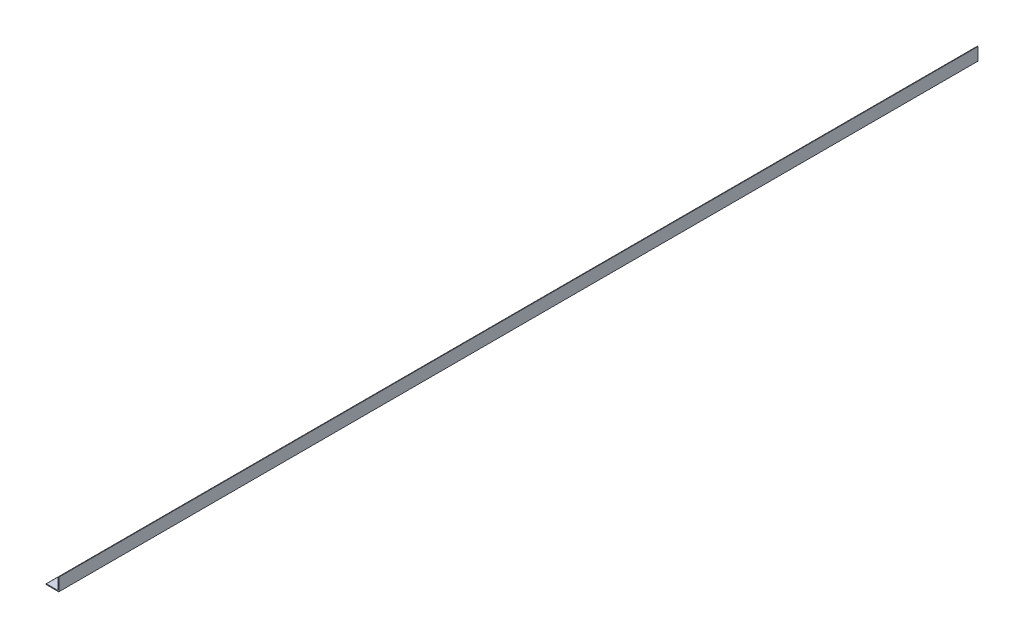
from build123d import *

# Parameters (mm, degrees)
BOSS_EXTRUDE1_DEPTH     = 914.4
F_1_4_20_TAPPED_HOLE1_D = 5.1054
CUT_EXTRUDE1_DEPTH      = 915.798166349


with BuildPart() as part:
    # Sketch2 → Boss-Extrude1 (new, symmetric)
    with BuildSketch(Plane.XY):
        with BuildLine():
            Line((-12.7, -12.7), (12.7, -12.7))
            Line((12.7, -12.7), (12.7, 12.7))
            Line((12.7, 12.7), (11.90625, 12.7))
            ThreePointArc((11.90625, 12.7), (11.344983992, 12.467516008), (11.1125, 11.90625))
            Line((11.1125, 11.90625), (11.1125, -9.5377))
            ThreePointArc((11.1125, -9.5377), (10.651251759, -10.651251759), (9.5377, -11.1125))
            Line((9.5377, -11.1125), (-11.90625, -11.1125))
            ThreePointArc((-11.90625, -11.1125), (-12.467516008, -11.344983992), (-12.7, -11.90625))
            Line((-12.7, -11.90625), (-12.7, -12.7))
        make_face()
    extrude(amount=BOSS_EXTRUDE1_DEPTH, both=True)

    # 1/4-20 Tapped Hole1 (through all)
    with Locations(Plane(origin=(0, -11.1125, 0), x_dir=(1, 0, 0), z_dir=(0, 1, 0))):
        with Locations((-1.5875, -705.104), (-1.5875, -249.428), (-1.5875, 661.924), (-1.5875, 206.248)):
            Hole(F_1_4_20_TAPPED_HOLE1_D / 2)

    # Sketch5 → Cut-Extrude1 (cut, through all)
    with BuildSketch(Plane(origin=(0, -11.1125, 0), x_dir=(1, 0, 0), z_dir=(0, 1, 0))):
        with BuildLine():
            Line((-4.6355, 701.675), (-4.6355, 720.725))
            ThreePointArc((-4.6355, 720.725), (-1.5875, 723.773), (1.4605, 720.725))
            Line((1.4605, 720.725), (1.4605, 701.675))
            ThreePointArc((1.4605, 701.675), (-1.5875, 698.627), (-4.6355, 701.675))
        make_face()
        with BuildLine():
            Line((1.4605, 304.8), (1.4605, 285.75))
            ThreePointArc((1.4605, 285.75), (-1.5875, 282.702), (-4.6355, 285.75))
            Line((-4.6355, 285.75), (-4.6355, 304.8))
            ThreePointArc((-4.6355, 304.8), (-1.5875, 307.848), (1.4605, 304.8))
        make_face()
        with BuildLine():
            Line((1.4605, -336.55), (1.4605, -317.5))
            ThreePointArc((1.4605, -317.5), (-1.5875, -314.452), (-4.6355, -317.5))
            Line((-4.6355, -317.5), (-4.6355, -336.55))
            ThreePointArc((-4.6355, -336.55), (-1.5875, -339.598), (1.4605, -336.55))
        make_face()
        with BuildLine():
            Line((-4.6355, -717.55), (-4.6355, -736.6))
            ThreePointArc((-4.6355, -736.6), (-1.5875, -739.648), (1.4605, -736.6))
            Line((1.4605, -736.6), (1.4605, -717.55))
            ThreePointArc((1.4605, -717.55), (-1.5875, -714.502), (-4.6355, -717.55))
        make_face()
    extrude(amount=-CUT_EXTRUDE1_DEPTH, mode=Mode.SUBTRACT)


solid = part.part
